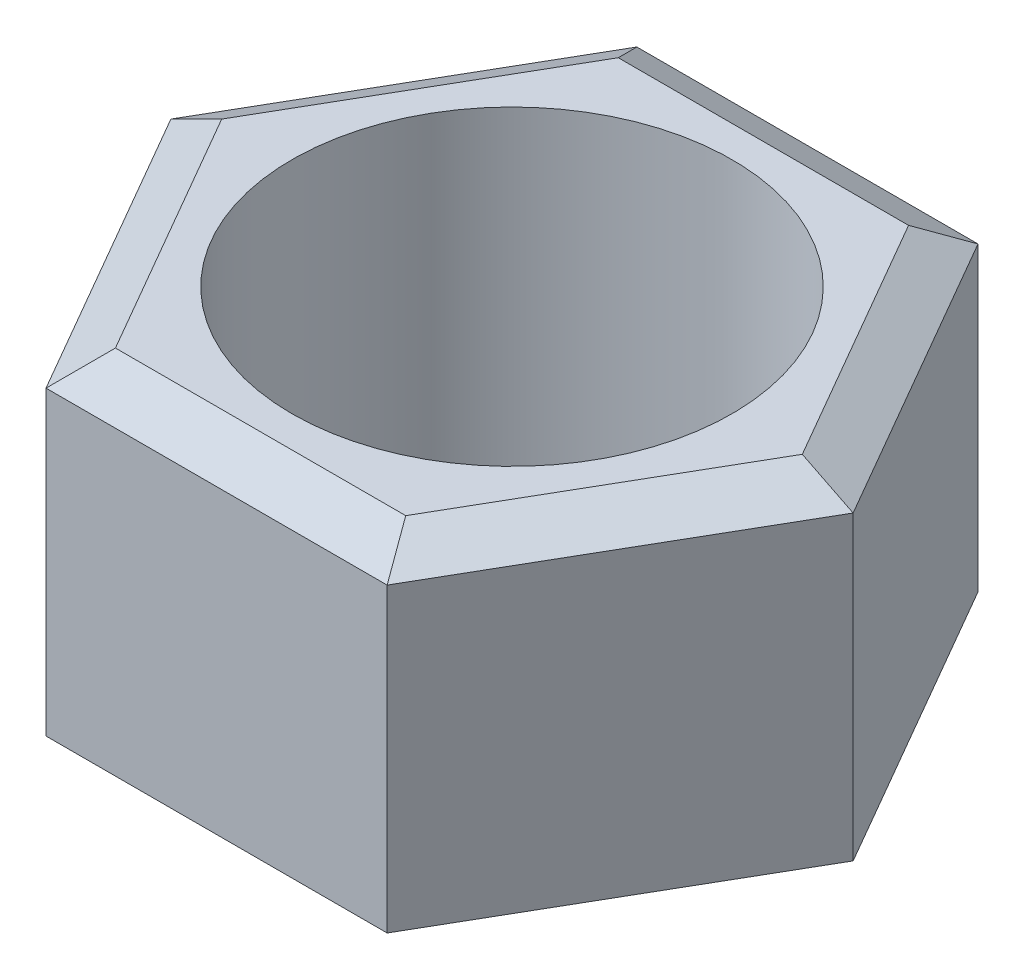
from build123d import *

# Parameters (mm, degrees)
SKETCH_1_R      = 5
EXTRUDE_1_DEPTH = 8
CHAMFER_1_SIZE  = 1
CHAMFER_1_SIZE2 = 0.577350269
CHAMFER_2_SIZE  = 1
CHAMFER_2_SIZE2 = 0.577350269


with BuildPart() as part:
    # Эскиз1 → Бобышка-Вытянуть1 (new body)
    with BuildSketch(Plane(origin=(0, 0, 0), x_dir=(1, 0, 0), z_dir=(0, 1, 0))):
        Polygon((-7.75, 0), (-3.875, -6.711696879), (3.875, -6.711696879), (7.75, 0), (3.875, 6.711696879), (-3.875, 6.711696879), align=None)
        Circle(SKETCH_1_R, mode=Mode.SUBTRACT)
    extrude(amount=EXTRUDE_1_DEPTH)

    # Фаска1
    chamfer_1_edges = [part.edges().sort_by_distance(p)[0] for p in [
        (0, 8, 6.711696879),
        (5.8125, 8, 3.35584844),
        (5.8125, 8, -3.35584844),
        (0, 8, -6.711696879),
        (-5.8125, 8, -3.35584844),
        (-5.8125, 8, 3.35584844),
    ]]
    chamfer_1_side = [part.faces().sort_by_distance(p)[0] for p in [
        (-5.634925192, 8, 3.253325576),
    ]]
    chamfer(chamfer_1_edges, length=CHAMFER_1_SIZE, length2=CHAMFER_1_SIZE2, reference=chamfer_1_side[0])

    # Фаска2
    chamfer_2_edges = [part.edges().sort_by_distance(p)[0] for p in [
        (0, 0, -6.711696879),
        (5.8125, 0, -3.35584844),
        (5.8125, 0, 3.35584844),
        (0, 0, 6.711696879),
        (-5.8125, 0, 3.35584844),
        (-5.8125, 0, -3.35584844),
    ]]
    chamfer_2_side = [part.faces().sort_by_distance(p)[0] for p in [
        (-5.634925192, 0, 3.253325576),
    ]]
    chamfer(chamfer_2_edges, length=CHAMFER_2_SIZE, length2=CHAMFER_2_SIZE2, reference=chamfer_2_side[0])


solid = part.part
